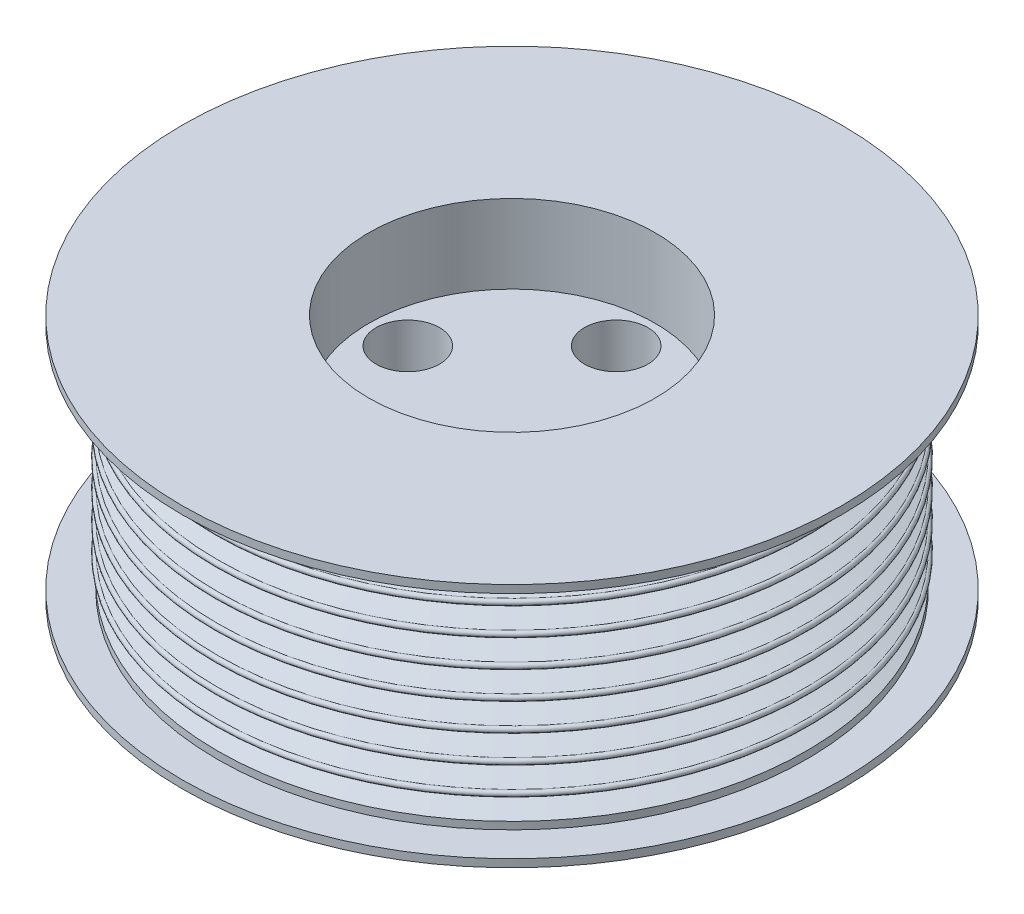
from build123d import *

# Parameters (mm, degrees)
SKETCH2_R                = 18.542
CUT_EXTRUDE1_DEPTH       = 10.16
F_5_16_CLEARANCE_HOLE1_D = 8.2042
CIRPATTERN1_COUNT        = 4


with BuildPart() as part:
    # Sketch1 → Revolve1 (revolve)
    with BuildSketch(Plane.XY):
        with BuildLine():
            Line((38.1, 13.90396), (38.1, 14.85646))
            Line((38.1, 14.85646), (42.672, 14.85646))
            Line((42.672, 14.85646), (42.672, 15.87246))
            Line((42.672, 15.87246), (38.1, 15.87246))
            Line((38.1, 15.87246), (0, 15.87246))
            Line((0, 15.87246), (0, -15.87246))
            Line((0, -15.87246), (38.1, -15.87246))
            Line((38.1, -15.87246), (42.672, -15.87246))
            Line((42.672, -15.87246), (42.672, -14.85646))
            Line((42.672, -14.85646), (38.1, -14.85646))
            Line((38.1, -14.85646), (38.1, -13.90396))
            Line((38.1, -13.90396), (35.287627164, -12.88034))
            ThreePointArc((35.287627164, -12.88034), (34.906627164, -12.49934), (35.287627164, -12.11834))
            Line((35.287627164, -12.11834), (38.1, -11.09472))
            ThreePointArc((38.1, -11.09472), (38.481, -10.71372), (38.1, -10.33272))
            Line((38.1, -10.33272), (35.287627164, -9.3091))
            ThreePointArc((35.287627164, -9.3091), (34.906627164, -8.9281), (35.287627164, -8.5471))
            Line((35.287627164, -8.5471), (38.1, -7.52348))
            ThreePointArc((38.1, -7.52348), (38.481, -7.14248), (38.1, -6.76148))
            Line((38.1, -6.76148), (35.287627164, -5.73786))
            ThreePointArc((35.287627164, -5.73786), (34.906627164, -5.35686), (35.287627164, -4.97586))
            Line((35.287627164, -4.97586), (38.1, -3.95224))
            ThreePointArc((38.1, -3.95224), (38.481, -3.57124), (38.1, -3.19024))
            Line((38.1, -3.19024), (35.287627164, -2.16662))
            ThreePointArc((35.287627164, -2.16662), (34.906627164, -1.78562), (35.287627164, -1.40462))
            Line((35.287627164, -1.40462), (38.1, -0.381))
            ThreePointArc((38.1, -0.381), (38.481, 0), (38.1, 0.381))
            Line((38.1, 0.381), (35.287627164, 1.40462))
            ThreePointArc((35.287627164, 1.40462), (34.906627164, 1.78562), (35.287627164, 2.16662))
            Line((35.287627164, 2.16662), (38.1, 3.19024))
            ThreePointArc((38.1, 3.19024), (38.481, 3.57124), (38.1, 3.95224))
            Line((38.1, 3.95224), (35.287627164, 4.97586))
            ThreePointArc((35.287627164, 4.97586), (34.906627164, 5.35686), (35.287627164, 5.73786))
            Line((35.287627164, 5.73786), (38.1, 6.76148))
            ThreePointArc((38.1, 6.76148), (38.481, 7.14248), (38.1, 7.52348))
            Line((38.1, 7.52348), (35.287627164, 8.5471))
            ThreePointArc((35.287627164, 8.5471), (34.906627164, 8.9281), (35.287627164, 9.3091))
            Line((35.287627164, 9.3091), (38.1, 10.33272))
            ThreePointArc((38.1, 10.33272), (38.481, 10.71372), (38.1, 11.09472))
            Line((38.1, 11.09472), (35.287627164, 12.11834))
            ThreePointArc((35.287627164, 12.11834), (34.906627164, 12.49934), (35.287627164, 12.88034))
            Line((35.287627164, 12.88034), (38.1, 13.90396))
        make_face()
    revolve(axis=Axis((0, 15.87246, 0), (0, -1, 0)))

    # Sketch2 → Cut-Extrude1 (cut)
    with BuildSketch(Plane(origin=(0, 15.87246, 0), x_dir=(1, 0, 0), z_dir=(0, 1, 0))):
        Circle(SKETCH2_R)
    extrude(amount=-CUT_EXTRUDE1_DEPTH, mode=Mode.SUBTRACT)

    # 5/16 Clearance Hole1 (through all)
    with Locations(Plane.XZ.offset(15.87246)):
        with Locations((0, -13.4874)):
            f_5_16_clearance_hole1 = Hole(F_5_16_CLEARANCE_HOLE1_D / 2)

    # CirPattern1: 5/16 Clearance Hole1 ×4 about axis
    cirpattern1_axis = Axis((0, 0, 0), (0, 1, 0))
    for i in range(1, CIRPATTERN1_COUNT):
        add(f_5_16_clearance_hole1.rotate(cirpattern1_axis, i * 360 / CIRPATTERN1_COUNT), mode=Mode.SUBTRACT)


solid = part.part
